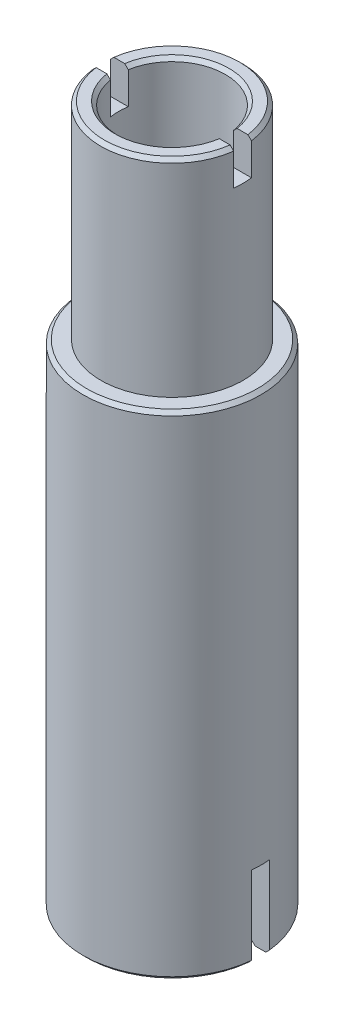
from build123d import *

# Parameters (mm, degrees)
SKETCH2_W          = 55
SKETCH2_H          = 5
CUT_EXTRUDE1_DEPTH = 10
SKETCH3_W          = 70
SKETCH3_H          = 5
CUT_EXTRUDE2_DEPTH = 23
CHAMFER1_SIZE      = 1


with BuildPart() as part:
    # Sketch1 → Revolve1 (revolve)
    with BuildSketch(Plane.XY):
        Polygon((20, -138.5), (25, -138.5), (25, 0), (20, 0), (20, 58), (15, 58), (15, -50), (20, -50), align=None)
    revolve(axis=Axis((0, 0, 0), (0, 1, 0)))

    # Sketch2 → Cut-Extrude1 (cut)
    with BuildSketch(Plane(origin=(0, 58, 0), x_dir=(1, 0, 0), z_dir=(0, 1, 0))):
        Rectangle(SKETCH2_W, SKETCH2_H)
    extrude(amount=-CUT_EXTRUDE1_DEPTH, mode=Mode.SUBTRACT)

    # Sketch3 → Cut-Extrude2 (cut)
    with BuildSketch(Plane(origin=(0, -138.5, 0), x_dir=(-1, 0, 0), z_dir=(0, -1, 0))):
        Rectangle(SKETCH3_W, SKETCH3_H)
    extrude(amount=-CUT_EXTRUDE2_DEPTH, mode=Mode.SUBTRACT)

    # Chamfer1
    chamfer1_edges = [part.edges().sort_by_distance(p)[0] for p in [
        (0, 58, 15),
        (0, 58, -15),
        (0, 58, 20),
        (0, 58, -20),
        (0, -138.5, 25),
        (0, -138.5, -25),
        (0, -138.5, 20),
        (0, -138.5, -20),
        (-15, -50, 0),
        (-25, 0, 0),
    ]]
    chamfer(chamfer1_edges, length=CHAMFER1_SIZE)


solid = part.part
